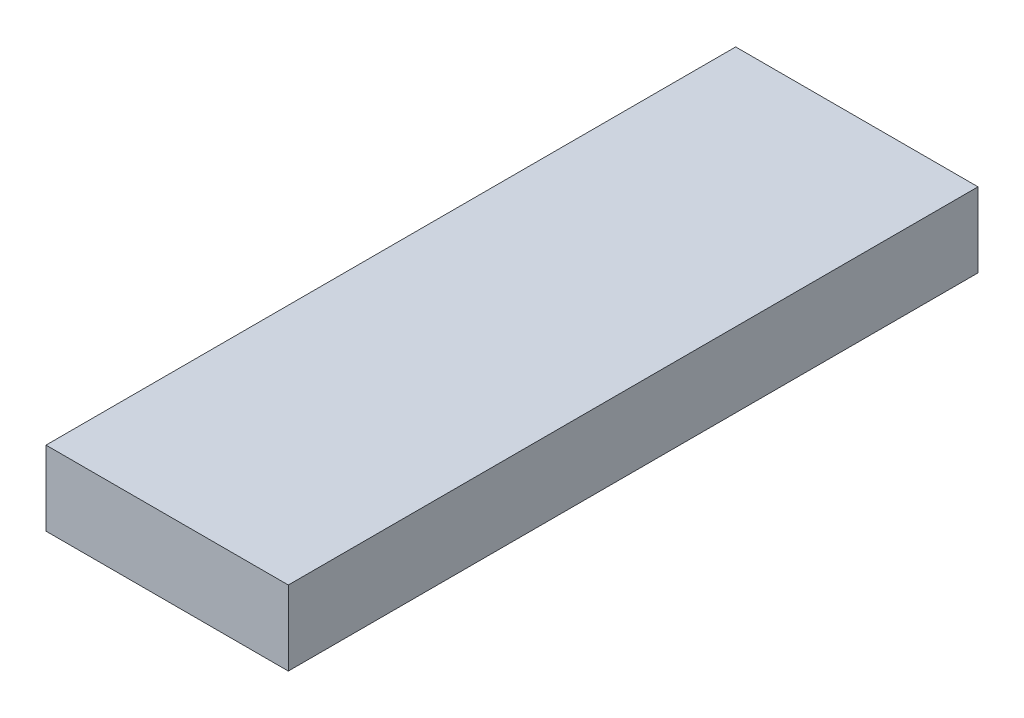
from build123d import *

# Parameters (mm, degrees)
SKETCH1_W           = 330.2
SKETCH1_H           = 939.8
BOSS_EXTRUDE1_DEPTH = 101.6


with BuildPart() as part:
    # Sketch1 → Boss-Extrude1 (new body)
    with BuildSketch(Plane(origin=(0, 0, 0), x_dir=(1, 0, 0), z_dir=(0, 1, 0))):
        with Locations((165.1, 469.9)):
            Rectangle(SKETCH1_W, SKETCH1_H)
    extrude(amount=BOSS_EXTRUDE1_DEPTH)


solid = part.part
